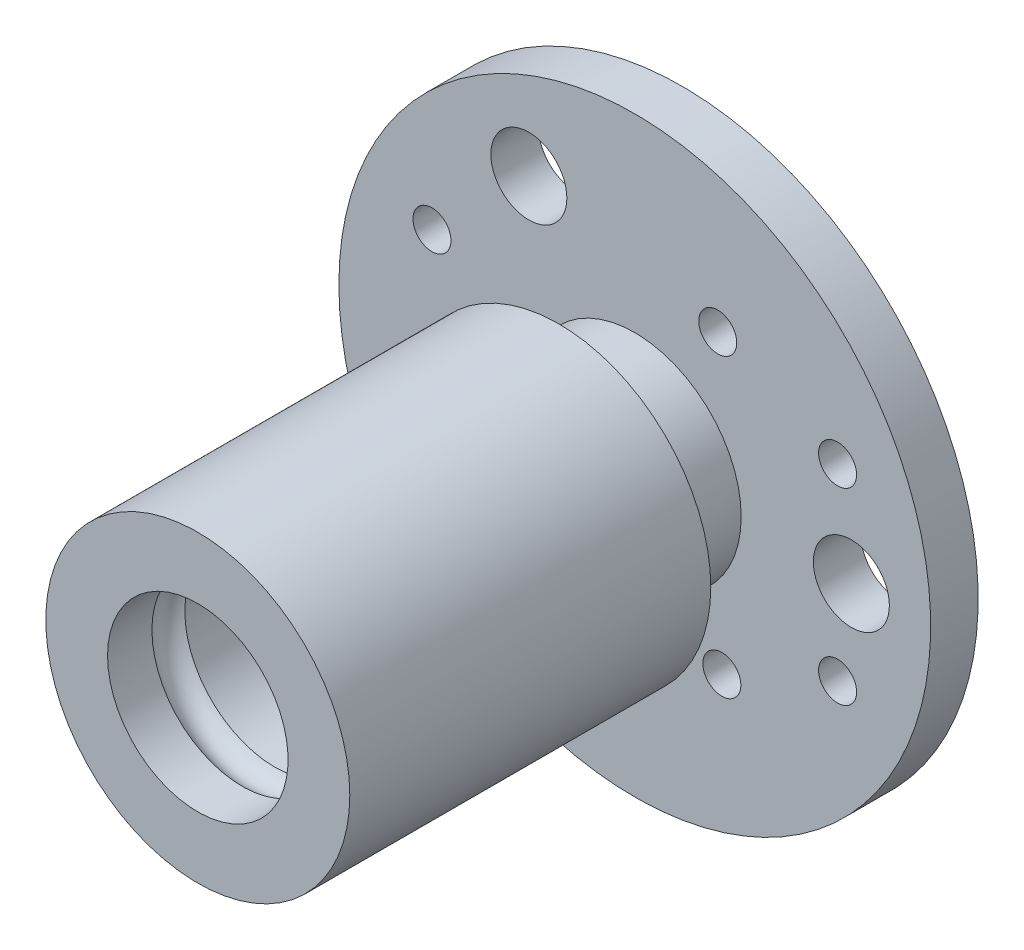
from build123d import *

# Parameters (mm, degrees)
SKETCH1_R           = 31.65
BOSS_EXTRUDE1_DEPTH = 5
CHAMFER1_SIZE       = 0.5
SKETCH2_R           = 11.2
BOSS_EXTRUDE2_DEPTH = 8
SKETCH3_R           = 16
BOSS_EXTRUDE3_DEPTH = 38
SKETCH5_R           = 9.5
CUT_EXTRUDE2_DEPTH  = 52
CUT_EXTRUDE3_REACH  = 53
SKETCH6_R           = 2
SKETCH6_R_2         = 4
SKETCH8_OUTSIDE_W   = 85.906
SKETCH8_OUTSIDE_H   = 85.906
SKETCH8_OUTSIDE_R   = 31.15
SKETCH8_OUTSIDE_R_2 = 4
CUT_EXTRUDE4_DEPTH  = 10


with BuildPart() as part:
    # Sketch1 → Boss-Extrude1 (new body)
    with BuildSketch(Plane.XY):
        Circle(SKETCH1_R)
    extrude(amount=BOSS_EXTRUDE1_DEPTH)

    # Chamfer1
    chamfer1_edges = [part.edges().sort_by_distance(p)[0] for p in [
        (-31.65, 0, 0),
        (-31.65, 0, 5),
    ]]
    chamfer(chamfer1_edges, length=CHAMFER1_SIZE)

    # Sketch2 → Boss-Extrude2 (add)
    with BuildSketch(Plane.XY.offset(5)):
        Circle(SKETCH2_R)
    extrude(amount=BOSS_EXTRUDE2_DEPTH)

    # Sketch3 → Boss-Extrude3 (add)
    with BuildSketch(Plane.XY.offset(13)):
        Circle(SKETCH3_R)
    extrude(amount=BOSS_EXTRUDE3_DEPTH)

    # Sketch5 → Cut-Extrude2 (cut, through all)
    with BuildSketch(Plane(origin=(0, 0, 0), x_dir=(-1, 0, 0), z_dir=(0, 0, -1))):
        Circle(SKETCH5_R)
    extrude(amount=-CUT_EXTRUDE2_DEPTH, mode=Mode.SUBTRACT)

    # Sketch6 → Cut-Extrude3 (cut, up to next)
    with BuildSketch(Plane(origin=(0, 0, 0), x_dir=(-1, 0, 0), z_dir=(0, 0, -1)), mode=Mode.PRIVATE) as cut_extrude3_sk1:
        with Locations((21.35, 9.9)):
            Circle(SKETCH6_R)
    cut_extrude3_tool1 = extrude(cut_extrude3_sk1.sketch, amount=-CUT_EXTRUDE3_REACH, mode=Mode.PRIVATE) & part.part
    add(cut_extrude3_tool1.solids().sort_by_distance((-21.35, 9.9, 0))[0], mode=Mode.SUBTRACT)
    # Sketch6 → Cut-Extrude3 (cut, up to next)
    with BuildSketch(Plane(origin=(0, 0, 0), x_dir=(-1, 0, 0), z_dir=(0, 0, -1)), mode=Mode.PRIVATE) as cut_extrude3_sk2:
        with Locations((-21.35, 9.9)):
            Circle(SKETCH6_R)
    cut_extrude3_tool2 = extrude(cut_extrude3_sk2.sketch, amount=-CUT_EXTRUDE3_REACH, mode=Mode.PRIVATE) & part.part
    add(cut_extrude3_tool2.solids().sort_by_distance((21.35, 9.9, 0))[0], mode=Mode.SUBTRACT)
    # Sketch6 → Cut-Extrude3 (cut, up to next)
    with BuildSketch(Plane(origin=(0, 0, 0), x_dir=(-1, 0, 0), z_dir=(0, 0, -1)), mode=Mode.PRIVATE) as cut_extrude3_sk3:
        with Locations((-21.35, -9.9)):
            Circle(SKETCH6_R)
    cut_extrude3_tool3 = extrude(cut_extrude3_sk3.sketch, amount=-CUT_EXTRUDE3_REACH, mode=Mode.PRIVATE) & part.part
    add(cut_extrude3_tool3.solids().sort_by_distance((21.35, -9.9, 0))[0], mode=Mode.SUBTRACT)
    # Sketch6 → Cut-Extrude3 (cut, up to next)
    with BuildSketch(Plane(origin=(0, 0, 0), x_dir=(-1, 0, 0), z_dir=(0, 0, -1)), mode=Mode.PRIVATE) as cut_extrude3_sk4:
        with Locations((21.35, -9.9)):
            Circle(SKETCH6_R)
    cut_extrude3_tool4 = extrude(cut_extrude3_sk4.sketch, amount=-CUT_EXTRUDE3_REACH, mode=Mode.PRIVATE) & part.part
    add(cut_extrude3_tool4.solids().sort_by_distance((-21.35, -9.9, 0))[0], mode=Mode.SUBTRACT)
    # Sketch6 → Cut-Extrude3 (cut, up to next)
    with BuildSketch(Plane(origin=(0, 0, 0), x_dir=(-1, 0, 0), z_dir=(0, 0, -1)), mode=Mode.PRIVATE) as cut_extrude3_sk5:
        with Locations((11.648195828, -19.6)):
            Circle(SKETCH6_R_2)
    cut_extrude3_tool5 = extrude(cut_extrude3_sk5.sketch, amount=-CUT_EXTRUDE3_REACH, mode=Mode.PRIVATE) & part.part
    add(cut_extrude3_tool5.solids().sort_by_distance((-11.648196, -19.6, 0))[0], mode=Mode.SUBTRACT)
    # Sketch6 → Cut-Extrude3 (cut, up to next)
    with BuildSketch(Plane(origin=(0, 0, 0), x_dir=(-1, 0, 0), z_dir=(0, 0, -1)), mode=Mode.PRIVATE) as cut_extrude3_sk6:
        with Locations((-8.732486564, 15.622964243)):
            Circle(SKETCH6_R)
    cut_extrude3_tool6 = extrude(cut_extrude3_sk6.sketch, amount=-CUT_EXTRUDE3_REACH, mode=Mode.PRIVATE) & part.part
    add(cut_extrude3_tool6.solids().sort_by_distance((8.732487, 15.622964, 0))[0], mode=Mode.SUBTRACT)
    # Sketch6 → Cut-Extrude3 (cut, up to next)
    with BuildSketch(Plane(origin=(0, 0, 0), x_dir=(-1, 0, 0), z_dir=(0, 0, -1)), mode=Mode.PRIVATE) as cut_extrude3_sk7:
        with Locations((-9.163640635, -15.374037324)):
            Circle(SKETCH6_R)
    cut_extrude3_tool7 = extrude(cut_extrude3_sk7.sketch, amount=-CUT_EXTRUDE3_REACH, mode=Mode.PRIVATE) & part.part
    add(cut_extrude3_tool7.solids().sort_by_distance((9.163641, -15.374037, 0))[0], mode=Mode.SUBTRACT)
    # Sketch6 → Cut-Extrude3 (cut, up to next)
    with BuildSketch(Plane(origin=(0, 0, 0), x_dir=(-1, 0, 0), z_dir=(0, 0, -1)), mode=Mode.PRIVATE) as cut_extrude3_sk8:
        with Locations((17.896127199, -0.248926919)):
            Circle(SKETCH6_R)
    cut_extrude3_tool8 = extrude(cut_extrude3_sk8.sketch, amount=-CUT_EXTRUDE3_REACH, mode=Mode.PRIVATE) & part.part
    add(cut_extrude3_tool8.solids().sort_by_distance((-17.896127, -0.248927, 0))[0], mode=Mode.SUBTRACT)

    # Sketch7 → Cut-Revolve3 (revolve, cut)
    with BuildSketch(Plane(origin=(0, 0, 0), x_dir=(1, 0, 0), z_dir=(0, 1, 0))):
        with BuildLine():
            Line((-8.5, -42.6), (-8.5, -46.6))
            ThreePointArc((-8.5, -46.6), (-10.5, -44.6), (-8.5, -42.6))
        make_face()
    revolve(axis=Axis((0, 0, 44.6), (0, 0, 1)), mode=Mode.SUBTRACT)

    # Sketch8 outside → Cut-Extrude4 (cut)
    with BuildSketch(Plane(origin=(0, 0, 0), x_dir=(-1, 0, 0), z_dir=(0, 0, -1))):
        Rectangle(SKETCH8_OUTSIDE_W, SKETCH8_OUTSIDE_H)
        Circle(SKETCH8_OUTSIDE_R, mode=Mode.SUBTRACT)
        with Locations((-22.798195828, -0.287633496)):
            Circle(SKETCH8_OUTSIDE_R_2)
        with Locations((11.15, 19.887633496)):
            Circle(SKETCH8_OUTSIDE_R_2)
    extrude(amount=-CUT_EXTRUDE4_DEPTH, mode=Mode.SUBTRACT)


solid = part.part
